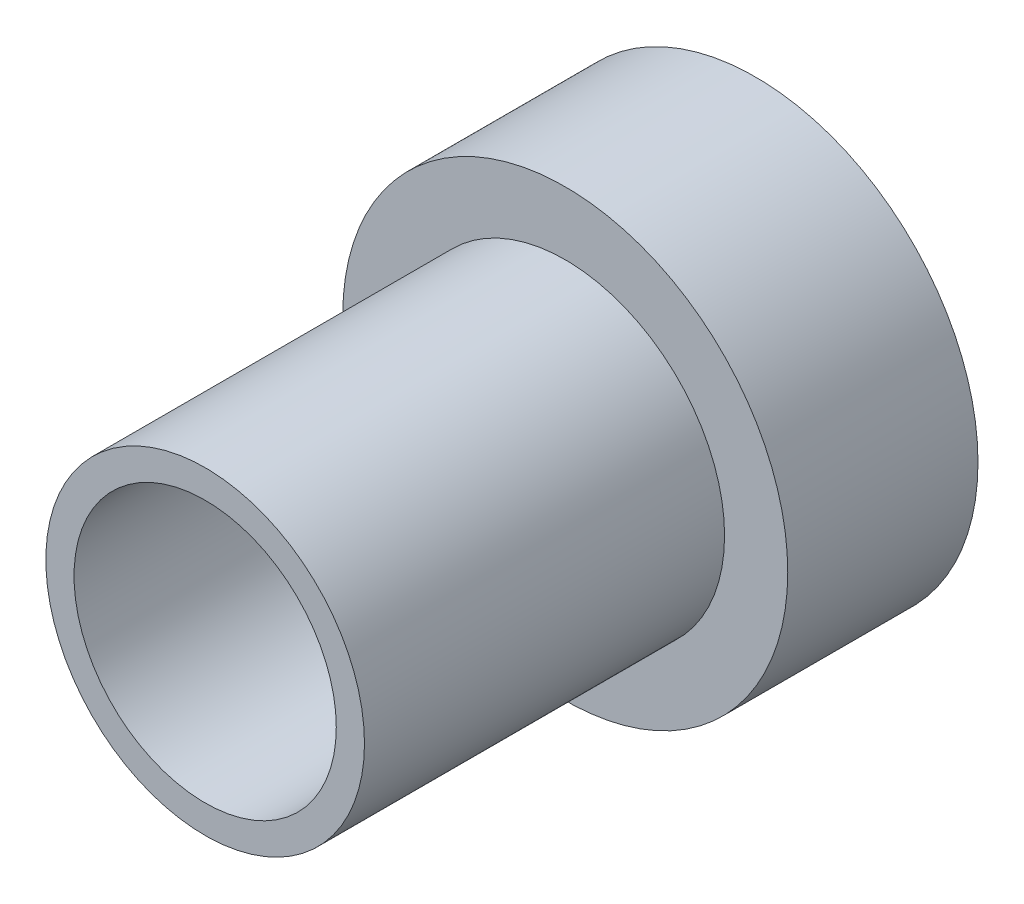
from build123d import *

# Parameters (mm, degrees)
SKETCH1_R           = 4.15925
SKETCH1_R_2         = 2.4511
BOSS_EXTRUDE1_DEPTH = 10.287
SKETCH2_OUTSIDE_W   = 13.444
SKETCH2_OUTSIDE_H   = 13.444
SKETCH2_OUTSIDE_R   = 2.97815
CUT_EXTRUDE1_DEPTH  = 6.731
CHAMFER1_SIZE       = 1.778
CHAMFER1_SIZE2      = 1.339819101


with BuildPart() as part:
    # Sketch1 → Boss-Extrude1 (new body)
    with BuildSketch(Plane.XY):
        Circle(SKETCH1_R)
        Circle(SKETCH1_R_2, mode=Mode.SUBTRACT)
    extrude(amount=BOSS_EXTRUDE1_DEPTH)

    # Sketch2 outside → Cut-Extrude1 (cut)
    with BuildSketch(Plane.XY.offset(10.287)):
        Rectangle(SKETCH2_OUTSIDE_W, SKETCH2_OUTSIDE_H)
        Circle(SKETCH2_OUTSIDE_R, mode=Mode.SUBTRACT)
    extrude(amount=-CUT_EXTRUDE1_DEPTH, mode=Mode.SUBTRACT)

    # Chamfer1
    chamfer1_edges = [part.edges().sort_by_distance(p)[0] for p in [
        (-2.4511, 0, 0),
    ]]
    chamfer1_side = [part.faces().sort_by_distance(p)[0] for p in [
        (-2.4511, 0, 5.1435),
    ]]
    chamfer(chamfer1_edges, length=CHAMFER1_SIZE, length2=CHAMFER1_SIZE2, reference=chamfer1_side[0])


solid = part.part
